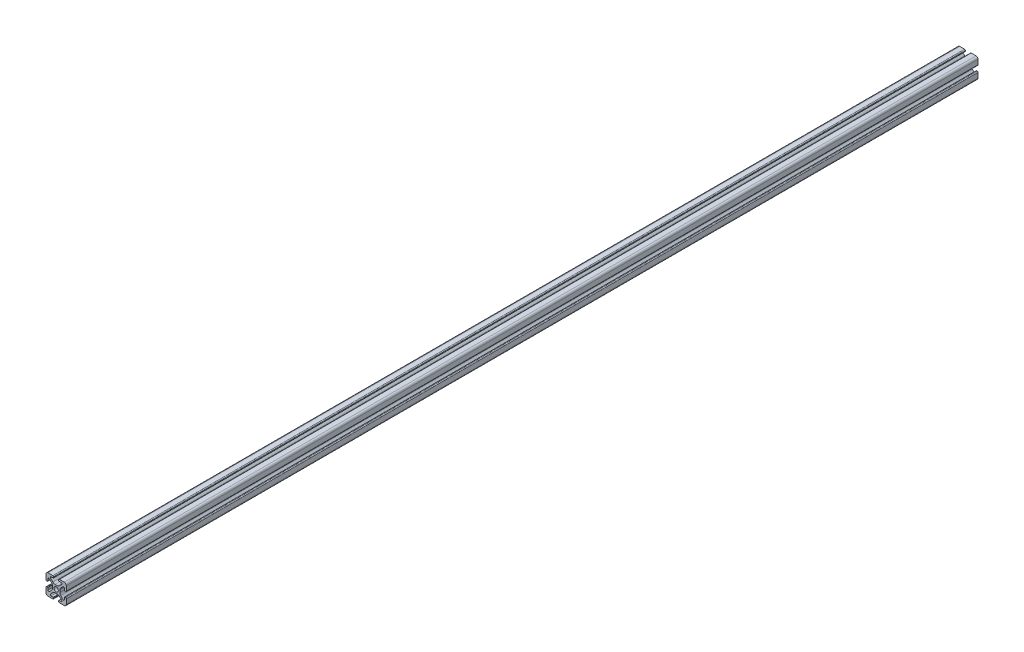
from build123d import *

# Parameters (mm, degrees)
SKETCH3_R                = 2.15
BOSS_EXTRUDE1_DEPTH      = 450
BOSS_EXTRUDE1_DEPTH_BACK = 450


with BuildPart() as part:
    # Sketch3 → Boss-Extrude1 (new body, two sides)
    with BuildSketch(Plane.XY) as boss_extrude1_sk:
        with BuildLine():
            Line((3.2874, 10), (8, 10))
            ThreePointArc((8, 10), (9.414213562, 9.414213562), (10, 8))
            Line((10, 8), (10, 3.2874))
            ThreePointArc((10, 3.2874), (9.76937588, 2.73062412), (9.2126, 2.5))
            Line((9.2126, 2.5), (8.5048, 2.5))
            ThreePointArc((8.5048, 2.5), (8.289273853, 2.589273853), (8.2, 2.8048))
            Line((8.2, 2.8048), (8.2, 4.9118))
            ThreePointArc((8.2, 4.9118), (7.682565253, 5.686195824), (6.769103096, 5.504496904))
            Line((6.769103096, 5.504496904), (4.478679656, 3.214073464))
            ThreePointArc((4.478679656, 3.214073464), (3.828361402, 2.240803418), (3.6, 1.092753121))
            Line((3.6, 1.092753121), (3.6, -1.092753121))
            ThreePointArc((3.6, -1.092753121), (3.828361402, -2.240803418), (4.478679656, -3.214073464))
            Line((4.478679656, -3.214073464), (6.769103096, -5.504496904))
            ThreePointArc((6.769103096, -5.504496904), (7.682565253, -5.686195824), (8.2, -4.9118))
            Line((8.2, -4.9118), (8.2, -2.8048))
            ThreePointArc((8.2, -2.8048), (8.289273853, -2.589273853), (8.5048, -2.5))
            Line((8.5048, -2.5), (9.2126, -2.5))
            ThreePointArc((9.2126, -2.5), (9.76937588, -2.73062412), (10, -3.2874))
            Line((10, -3.2874), (10, -8))
            ThreePointArc((10, -8), (9.414213562, -9.414213562), (8, -10))
            Line((8, -10), (3.2874, -10))
            ThreePointArc((3.2874, -10), (2.73062412, -9.76937588), (2.5, -9.2126))
            Line((2.5, -9.2126), (2.5, -8.5048))
            ThreePointArc((2.5, -8.5048), (2.589273853, -8.289273853), (2.8048, -8.2))
            Line((2.8048, -8.2), (4.9118, -8.2))
            ThreePointArc((4.9118, -8.2), (5.686195824, -7.682565253), (5.504496904, -6.769103096))
            Line((5.504496904, -6.769103096), (3.214073464, -4.478679656))
            ThreePointArc((3.214073464, -4.478679656), (2.240803418, -3.828361402), (1.092753121, -3.6))
            Line((1.092753121, -3.6), (-1.092753121, -3.6))
            ThreePointArc((-1.092753121, -3.6), (-2.240803418, -3.828361402), (-3.214073464, -4.478679656))
            Line((-3.214073464, -4.478679656), (-5.504496904, -6.769103096))
            ThreePointArc((-5.504496904, -6.769103096), (-5.686195824, -7.682565253), (-4.9118, -8.2))
            Line((-4.9118, -8.2), (-2.8048, -8.2))
            ThreePointArc((-2.8048, -8.2), (-2.589273853, -8.289273853), (-2.5, -8.5048))
            Line((-2.5, -8.5048), (-2.5, -9.2126))
            ThreePointArc((-2.5, -9.2126), (-2.73062412, -9.76937588), (-3.2874, -10))
            Line((-3.2874, -10), (-8, -10))
            ThreePointArc((-8, -10), (-9.414213562, -9.414213562), (-10, -8))
            Line((-10, -8), (-10, -3.2874))
            ThreePointArc((-10, -3.2874), (-9.76937588, -2.73062412), (-9.2126, -2.5))
            Line((-9.2126, -2.5), (-8.5048, -2.5))
            ThreePointArc((-8.5048, -2.5), (-8.289273853, -2.589273853), (-8.2, -2.8048))
            Line((-8.2, -2.8048), (-8.2, -4.9118))
            ThreePointArc((-8.2, -4.9118), (-7.682565253, -5.686195824), (-6.769103096, -5.504496904))
            Line((-6.769103096, -5.504496904), (-4.478679656, -3.214073464))
            ThreePointArc((-4.478679656, -3.214073464), (-3.828361402, -2.240803418), (-3.6, -1.092753121))
            Line((-3.6, -1.092753121), (-3.6, 1.092753121))
            ThreePointArc((-3.6, 1.092753121), (-3.828361402, 2.240803418), (-4.478679656, 3.214073464))
            Line((-4.478679656, 3.214073464), (-6.769103096, 5.504496904))
            ThreePointArc((-6.769103096, 5.504496904), (-7.682565253, 5.686195824), (-8.2, 4.9118))
            Line((-8.2, 4.9118), (-8.2, 2.8048))
            ThreePointArc((-8.2, 2.8048), (-8.289273853, 2.589273853), (-8.5048, 2.5))
            Line((-8.5048, 2.5), (-9.2126, 2.5))
            ThreePointArc((-9.2126, 2.5), (-9.76937588, 2.73062412), (-10, 3.2874))
            Line((-10, 3.2874), (-10, 8))
            ThreePointArc((-10, 8), (-9.414213562, 9.414213562), (-8, 10))
            Line((-8, 10), (-3.2874, 10))
            ThreePointArc((-3.2874, 10), (-2.73062412, 9.76937588), (-2.5, 9.2126))
            Line((-2.5, 9.2126), (-2.5, 8.5048))
            ThreePointArc((-2.5, 8.5048), (-2.589273853, 8.289273853), (-2.8048, 8.2))
            Line((-2.8048, 8.2), (-4.9118, 8.2))
            ThreePointArc((-4.9118, 8.2), (-5.686195824, 7.682565253), (-5.504496904, 6.769103096))
            Line((-5.504496904, 6.769103096), (-3.214073464, 4.478679656))
            ThreePointArc((-3.214073464, 4.478679656), (-2.240803418, 3.828361402), (-1.092753121, 3.6))
            Line((-1.092753121, 3.6), (1.092753121, 3.6))
            ThreePointArc((1.092753121, 3.6), (2.240803418, 3.828361402), (3.214073464, 4.478679656))
            Line((3.214073464, 4.478679656), (5.504496904, 6.769103096))
            ThreePointArc((5.504496904, 6.769103096), (5.686195824, 7.682565253), (4.9118, 8.2))
            Line((4.9118, 8.2), (2.8048, 8.2))
            ThreePointArc((2.8048, 8.2), (2.589273853, 8.289273853), (2.5, 8.5048))
            Line((2.5, 8.5048), (2.5, 9.2126))
            ThreePointArc((2.5, 9.2126), (2.73062412, 9.76937588), (3.2874, 10))
        make_face()
        Circle(SKETCH3_R, mode=Mode.SUBTRACT)
    extrude(amount=BOSS_EXTRUDE1_DEPTH)
    extrude(boss_extrude1_sk.sketch, amount=-BOSS_EXTRUDE1_DEPTH_BACK)


solid = part.part
